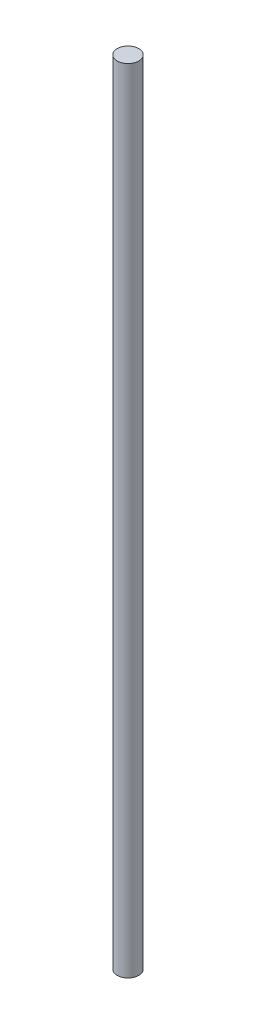
from build123d import *

# Parameters (mm, degrees)
SKETCH2_R           = 1.075
BOSS_EXTRUDE1_DEPTH = 79


with BuildPart() as part:
    # Sketch2 → Boss-Extrude1 (new body)
    with BuildSketch(Plane(origin=(0, 0, 0), x_dir=(1, 0, 0), z_dir=(0, 1, 0))):
        Circle(SKETCH2_R)
    extrude(amount=BOSS_EXTRUDE1_DEPTH)


solid = part.part
